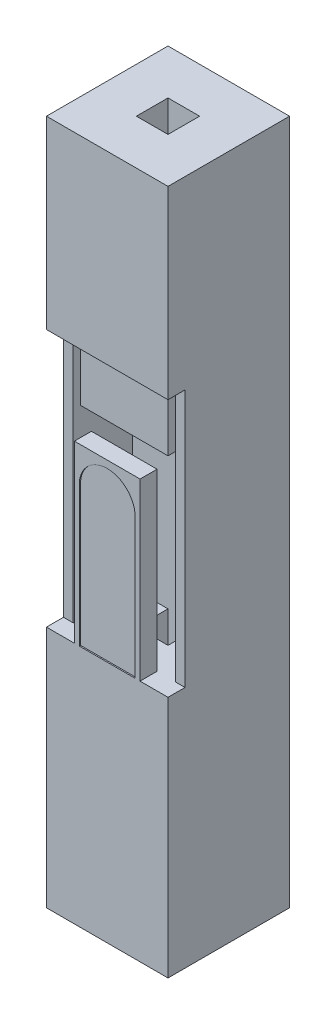
from build123d import *

# Parameters (mm, degrees)
SKETCH2_W           = 2.5
SKETCH2_H           = 2.5
BOSS_EXTRUDE1_DEPTH = 7.05
PINHOLE_REACH       = 16.1
SKETCH3_W           = 0.65
SKETCH3_H           = 0.65
CUT_EXTRUDE2_DEPTH  = 0.35
SKETCH5_W           = 2.1
SKETCH5_H           = 5.3
CUT_EXTRUDE3_DEPTH  = 1.225
CUT_EXTRUDE5_DEPTH  = 0.025
SKETCH7_W           = 2.1
SKETCH7_H           = 2.1
CUT_EXTRUDE6_DEPTH  = 4
SKETCH9_W           = 0.15
SKETCH9_H           = 1
HOLDER_1_DEPTH      = 1.075
SKETCH10_W          = 1.8
SKETCH10_H          = 1
HOLDER_2_DEPTH      = 0.15


with BuildPart() as part:
    # Sketch2 → Boss-Extrude1 (new body, symmetric)
    with BuildSketch(Plane(origin=(0, 0, 0), x_dir=(1, 0, 0), z_dir=(0, 1, 0))):
        Rectangle(SKETCH2_W, SKETCH2_H)
    extrude(amount=BOSS_EXTRUDE1_DEPTH, both=True)

    # Sketch3 → Pinhole (cut, up to next)
    with BuildSketch(Plane(origin=(0, 7.05, 0), x_dir=(1, 0, 0), z_dir=(0, 1, 0)), mode=Mode.PRIVATE) as pinhole_sk1:
        Rectangle(SKETCH3_W, SKETCH3_H)
    pinhole_tool1 = extrude(pinhole_sk1.sketch, amount=-PINHOLE_REACH, mode=Mode.PRIVATE) & part.part
    add(pinhole_tool1.solids().sort_by_distance((0, 7.05, 0))[0], mode=Mode.SUBTRACT)

    # Sketch4 → Cut-Extrude2 (cut)
    with BuildSketch(Plane.XY.offset(1.25)):
        Polygon((-1.25, 3.25), (1.25, 3.25), (1.25, -2.05), (0.675, -2.05), (0.675, 1.55), (-0.675, 1.55), (-0.675, -2.05), (-1.25, -2.05), align=None)
    extrude(amount=-CUT_EXTRUDE2_DEPTH, mode=Mode.SUBTRACT)

    # Sketch5 → Cut-Extrude3 (cut)
    with BuildSketch(Plane.XY.offset(0.9)):
        with Locations((0, 0.6)):
            Rectangle(SKETCH5_W, SKETCH5_H)
    extrude(amount=-CUT_EXTRUDE3_DEPTH, mode=Mode.SUBTRACT)

    # Sketch6 → Cut-Extrude5 (cut)
    with BuildSketch(Plane.XY.offset(1.25)):
        with BuildLine():
            Line((-0.575, 0.825), (-0.575, -2.05))
            Line((-0.575, -2.05), (0.575, -2.05))
            Line((0.575, -2.05), (0.575, 0.825))
            ThreePointArc((0.575, 0.825), (0, 1.4), (-0.575, 0.825))
        make_face()
    extrude(amount=-CUT_EXTRUDE5_DEPTH, mode=Mode.SUBTRACT)

    # Sketch7 → Cut-Extrude6 (cut)
    with BuildSketch(Plane.XZ.offset(7.05)):
        Rectangle(SKETCH7_W, SKETCH7_H)
    extrude(amount=-CUT_EXTRUDE6_DEPTH, mode=Mode.SUBTRACT)

    # Sketch9 → Holder-1 (add)
    with BuildSketch(Plane.XY.offset(-0.325)):
        with Locations((-0.825, 2.4)):
            Rectangle(SKETCH9_W, SKETCH9_H)
        with Locations((0.825, 2.4)):
            Rectangle(SKETCH9_W, SKETCH9_H)
    extrude(amount=HOLDER_1_DEPTH)

    # Sketch10 → Holder-2 (add)
    with BuildSketch(Plane.XY.offset(0.75)):
        with Locations((0, 2.4)):
            Rectangle(SKETCH10_W, SKETCH10_H)
    extrude(amount=HOLDER_2_DEPTH)


solid = part.part
